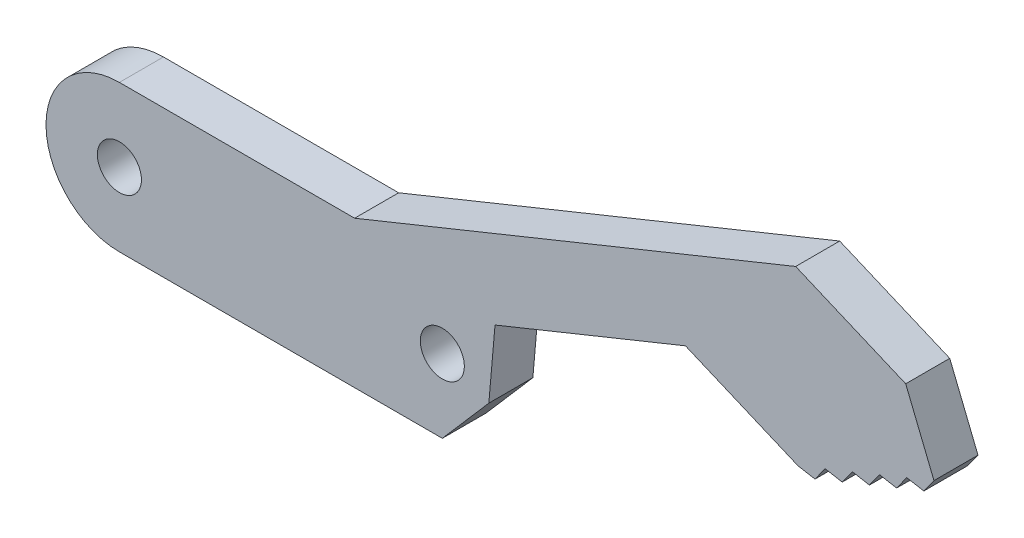
from build123d import *

# Parameters (mm, degrees)
SKETCH2_R               = 1.5
BOSS_EXTRUDE1_DEPTH     = 3
BOSS_EXTRUDE2_DEPTH     = 3
CUT_EXTRUDE1_DEPTH      = 3
CUT_EXTRUDE2_DEPTH      = 1
CUT_EXTRUDE2_DEPTH_BACK = 4


with BuildPart() as part:
    # Sketch2 → Boss-Extrude1 (new body)
    with BuildSketch(Plane.XY):
        with BuildLine():
            Line((11, 5), (-11, 5))
            ThreePointArc((-11, 5), (-16, 0), (-11, -5))
            Line((-11, -5), (11, -5))
            ThreePointArc((11, -5), (16, 0), (11, 5))
        make_face()
        with Locations((-11, 0)):
            Circle(SKETCH2_R, mode=Mode.SUBTRACT)
        with Locations((11, 0)):
            Circle(SKETCH2_R, mode=Mode.SUBTRACT)
    extrude(amount=BOSS_EXTRUDE1_DEPTH)

    # Sketch3 → Boss-Extrude2 (add)
    with BuildSketch(Plane.XY.offset(3)):
        with BuildLine():
            Line((44.729340863, 8.668642725), (35.461430272, 4.9128694))
            Line((35.461430272, 4.9128694), (35.224816552, 5.496747767))
            Line((35.224816552, 5.496747767), (27.564491501, 8.738899793))
            Line((27.564491501, 8.738899793), (14.589416673, 3.480817138))
            ThreePointArc((14.589416673, 3.480817138), (12.94883482, 4.604567607), (11, 5))
            Line((11, 5), (5.025381266, 5))
            Line((5.025381266, 5), (40.405753968, 19.337714926))
            Line((40.405753968, 19.337714926), (44.729340863, 8.668642725))
        make_face()
    extrude(amount=-BOSS_EXTRUDE2_DEPTH)

    # Sketch5 → Cut-Extrude1 (cut)
    with BuildSketch(Plane.XY.offset(3)):
        Polygon((40.405753968, 19.337714926), (42.567547416, 14.003178826), (35.071217868, 17.175921479), align=None)
    extrude(amount=-CUT_EXTRUDE1_DEPTH, mode=Mode.SUBTRACT)

    # Sketch6 → Cut-Extrude2 (cut, two sides)
    with BuildSketch(Plane.XY.offset(3)) as cut_extrude2_sk:
        Polygon((40.785562907, 7.750211762), (40.095385567, 6.790756063), (41.948967686, 7.541910728), align=None)
        Polygon((38.931980789, 6.999057097), (38.241803449, 6.039601398), (40.095385567, 6.790756063), align=None)
        Polygon((37.078398671, 6.247902432), (36.388221331, 5.288446733), (38.241803449, 6.039601398), align=None)
        Polygon((36.388221331, 5.288446733), (35.224816552, 5.496747767), (35.461430272, 4.9128694), align=None)
        Polygon((42.639145025, 8.501366427), (41.948967686, 7.541910728), (43.802549804, 8.293065393), align=None)
        Polygon((44.492727144, 9.252521092), (43.802549804, 8.293065393), (44.729340863, 8.668642725), align=None)
        with BuildLine():
            ThreePointArc((11, -5), (15.604567607, -1.94883482), (14.589416673, 3.480817138))
            Line((14.589416673, 3.480817138), (14.167937437, -1.340796208))
            Line((14.167937437, -1.340796208), (11, -5))
        make_face()
    extrude(amount=CUT_EXTRUDE2_DEPTH, mode=Mode.SUBTRACT)
    extrude(cut_extrude2_sk.sketch, amount=-CUT_EXTRUDE2_DEPTH_BACK, mode=Mode.SUBTRACT)


solid = part.part
